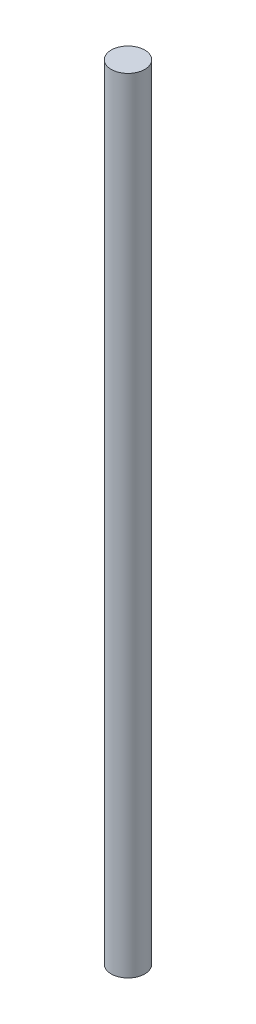
from build123d import *

# Parameters (mm, degrees)
SKETCH1_R           = 1.905
BOSS_EXTRUDE1_DEPTH = 88.9


with BuildPart() as part:
    # Sketch1 → Boss-Extrude1 (new body)
    with BuildSketch(Plane(origin=(0, 0, 0), x_dir=(1, 0, 0), z_dir=(0, 1, 0))):
        Circle(SKETCH1_R)
    extrude(amount=BOSS_EXTRUDE1_DEPTH)


solid = part.part
